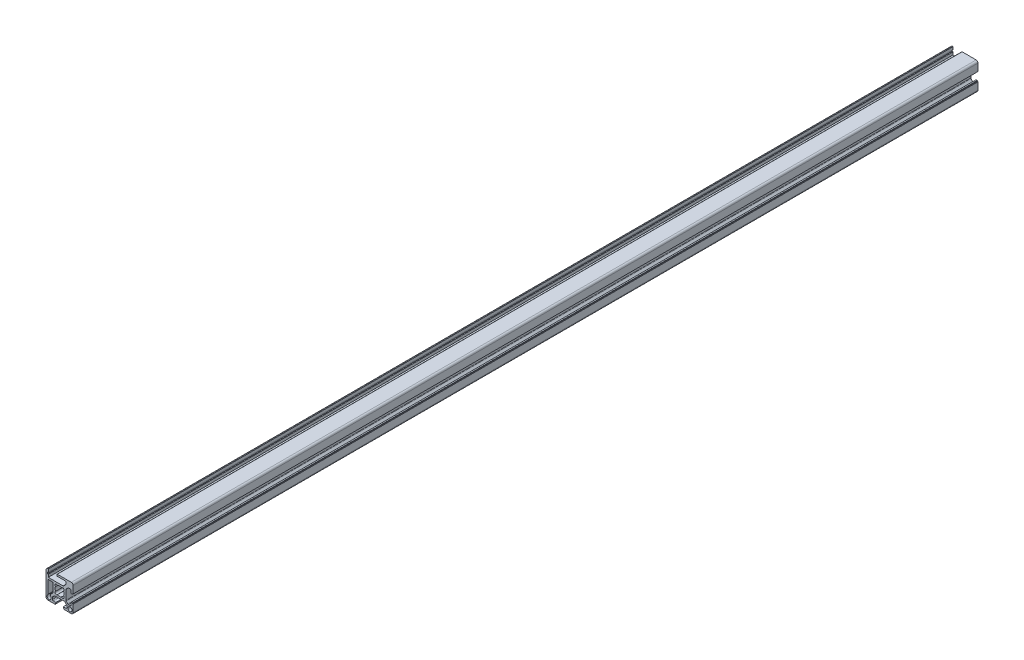
from build123d import *

# Parameters (mm, degrees)
SKETCH_1_R      = 2.25
EXTRUDE_1_DEPTH = 1000


with BuildPart() as part:
    # 草图1 → 拉伸1 (new body)
    with BuildSketch(Plane.XY):
        with BuildLine():
            Line((94.498219996, 123.603787887), (95.498219996, 123.603787887))
            Line((95.498219996, 123.603787887), (95.498219996, 120.604545229))
            Line((95.498219996, 120.604545229), (111.7555793, 120.604545229))
            ThreePointArc((111.7555793, 120.604545229), (112.138262733, 120.680665697), (112.462686082, 120.897438448))
            Line((112.462686082, 120.897438448), (114.705326774, 123.140079141))
            ThreePointArc((114.705326774, 123.140079141), (114.922099526, 123.46450249), (114.998219993, 123.847185922))
            Line((114.998219993, 123.847185922), (114.998219993, 125.604545228))
            ThreePointArc((114.998219993, 125.604545228), (114.705326774, 126.311652009), (113.998219993, 126.604545228))
            Line((113.998219993, 126.604545228), (104.998159012, 126.604545228))
            Line((104.998159012, 126.604545228), (104.998159012, 128.104545228))
            ThreePointArc((104.998159012, 128.104545228), (105.144605621, 128.458098618), (105.498159012, 128.604545228))
            Line((105.498159012, 128.604545228), (120.998159011, 128.604545228))
            ThreePointArc((120.998159011, 128.604545228), (122.412372573, 128.01875879), (122.998159011, 126.604545228))
            Line((122.998159011, 126.604545228), (122.998159011, 118.504545232))
            Line((122.998159011, 118.504545232), (122.198159011, 118.504545232))
            Line((122.198159011, 118.504545232), (122.198159011, 117.704545232))
            Line((122.198159011, 117.704545232), (120.798219991, 117.704545232))
            Line((120.798219991, 117.704545232), (120.798219991, 120.604545232))
            ThreePointArc((120.798219991, 120.604545232), (120.505326773, 121.311652013), (119.798219991, 121.604545232))
            Line((119.798219991, 121.604545232), (117.826647118, 121.604545232))
            ThreePointArc((117.826647118, 121.604545232), (117.443963686, 121.528424765), (117.119540337, 121.311652013))
            Line((117.119540337, 121.311652013), (115.291113212, 119.483224889))
            ThreePointArc((115.291113212, 119.483224889), (115.074340461, 119.15880154), (114.998219993, 118.776118107))
            Line((114.998219993, 118.776118107), (114.998219993, 108.432972357))
            ThreePointArc((114.998219993, 108.432972357), (115.074340461, 108.050288925), (115.291113212, 107.725865576))
            Line((115.291113212, 107.725865576), (117.119540337, 105.897438451))
            ThreePointArc((117.119540337, 105.897438451), (117.443963686, 105.6806657), (117.826647118, 105.604545232))
            Line((117.826647118, 105.604545232), (119.798219991, 105.604545232))
            ThreePointArc((119.798219991, 105.604545232), (120.505326773, 105.897438451), (120.798219991, 106.604545232))
            Line((120.798219991, 106.604545232), (120.798219991, 109.504545225))
            Line((120.798219991, 109.504545225), (122.198159011, 109.504545225))
            Line((122.198159011, 109.504545225), (122.198159011, 108.704545225))
            Line((122.198159011, 108.704545225), (122.998159011, 108.704545225))
            Line((122.998159011, 108.704545225), (122.998159011, 100.60454523))
            ThreePointArc((122.998159011, 100.60454523), (122.412372573, 99.190331667), (120.998159011, 98.60454523))
            Line((120.998159011, 98.60454523), (112.898159016, 98.60454523))
            Line((112.898159016, 98.60454523), (112.898159016, 99.40454523))
            Line((112.898159016, 99.40454523), (112.098159016, 99.40454523))
            Line((112.098159016, 99.40454523), (112.098159016, 100.804545237))
            Line((112.098159016, 100.804545237), (114.998219996, 100.804545237))
            ThreePointArc((114.998219996, 100.804545237), (115.705326777, 101.097438456), (115.998219996, 101.804545237))
            Line((115.998219996, 101.804545237), (115.998219996, 103.77611811))
            ThreePointArc((115.998219996, 103.77611811), (115.922099529, 104.158801543), (115.705326777, 104.483224892))
            Line((115.705326777, 104.483224892), (113.876899653, 106.311652016))
            ThreePointArc((113.876899653, 106.311652016), (113.552476304, 106.528424768), (113.169792871, 106.604545235))
            Line((113.169792871, 106.604545235), (102.826647121, 106.604545235))
            ThreePointArc((102.826647121, 106.604545235), (102.443963688, 106.528424768), (102.11954034, 106.311652016))
            Line((102.11954034, 106.311652016), (100.291113215, 104.483224892))
            ThreePointArc((100.291113215, 104.483224892), (100.074340464, 104.158801543), (99.998219996, 103.77611811))
            Line((99.998219996, 103.77611811), (99.998219996, 101.804545237))
            ThreePointArc((99.998219996, 101.804545237), (100.291113215, 101.097438456), (100.998219996, 100.804545237))
            Line((100.998219996, 100.804545237), (103.898159009, 100.804545237))
            Line((103.898159009, 100.804545237), (103.898159009, 99.40454523))
            Line((103.898159009, 99.40454523), (103.098159009, 99.40454523))
            Line((103.098159009, 99.40454523), (103.098159009, 98.60454523))
            Line((103.098159009, 98.60454523), (94.998159011, 98.60454523))
            ThreePointArc((94.998159011, 98.60454523), (93.583945449, 99.190331667), (92.998159011, 100.60454523))
            Line((92.998159011, 100.60454523), (92.998159011, 126.604545228))
            ThreePointArc((92.998159011, 126.604545228), (93.583945449, 128.01875879), (94.998159011, 128.604545228))
            Line((94.998159011, 128.604545228), (95.498219996, 128.604545228))
            Line((95.498219996, 128.604545228), (95.498219996, 125.603787887))
            Line((95.498219996, 125.603787887), (94.498219996, 125.603787887))
            Line((94.498219996, 125.603787887), (94.498219996, 123.603787887))
        make_face()
        with Locations((119.498219995, 102.104545233)):
            Circle(SKETCH_1_R, mode=Mode.SUBTRACT)
        with BuildLine():
            Line((97.998219996, 104.1812012), (97.998219996, 105.19033167))
            ThreePointArc((97.998219996, 105.19033167), (98.074340464, 105.573015102), (98.291113215, 105.897438451))
            Line((98.291113215, 105.897438451), (100.70532678, 108.311652016))
            ThreePointArc((100.70532678, 108.311652016), (100.922099531, 108.636075365), (100.998219999, 109.018758797))
            Line((100.998219999, 109.018758797), (100.998219999, 117.604545229))
            ThreePointArc((100.998219999, 117.604545229), (100.70532678, 118.311652011), (99.998219999, 118.604545229))
            Line((99.998219999, 118.604545229), (95.198219996, 118.604545229))
            Line((95.198219996, 118.604545229), (95.198219996, 104.400737733))
            ThreePointArc((95.198219996, 104.400737733), (95.122257957, 104.018437006), (94.905912304, 103.694216964))
            ThreePointArc((94.905912304, 103.694216964), (96.395419712, 99.856894882), (98.228989227, 103.542230133))
            ThreePointArc((98.228989227, 103.542230133), (98.057680053, 103.841518089), (97.998219996, 104.1812012))
        make_face(mode=Mode.SUBTRACT)
        with BuildLine():
            ThreePointArc((103.573125257, 115.932320253), (102.998219996, 113.604545232), (103.573125257, 111.276770211))
            ThreePointArc((103.573125257, 111.276770211), (103.402025918, 109.008351155), (105.670444975, 109.179450493))
            ThreePointArc((105.670444975, 109.179450493), (107.998219996, 108.604545232), (110.325995017, 109.179450493))
            ThreePointArc((110.325995017, 109.179450493), (112.594414074, 109.008351155), (112.423314735, 111.276770211))
            ThreePointArc((112.423314735, 111.276770211), (112.998219996, 113.604545232), (112.423314735, 115.932320253))
            ThreePointArc((112.423314735, 115.932320253), (112.594414074, 118.20073931), (110.325995017, 118.029639971))
            ThreePointArc((110.325995017, 118.029639971), (107.998219996, 118.604545232), (105.670444975, 118.029639971))
            ThreePointArc((105.670444975, 118.029639971), (103.402025918, 118.20073931), (103.573125257, 115.932320253))
        make_face(mode=Mode.SUBTRACT)
    extrude(amount=EXTRUDE_1_DEPTH)


solid = part.part
